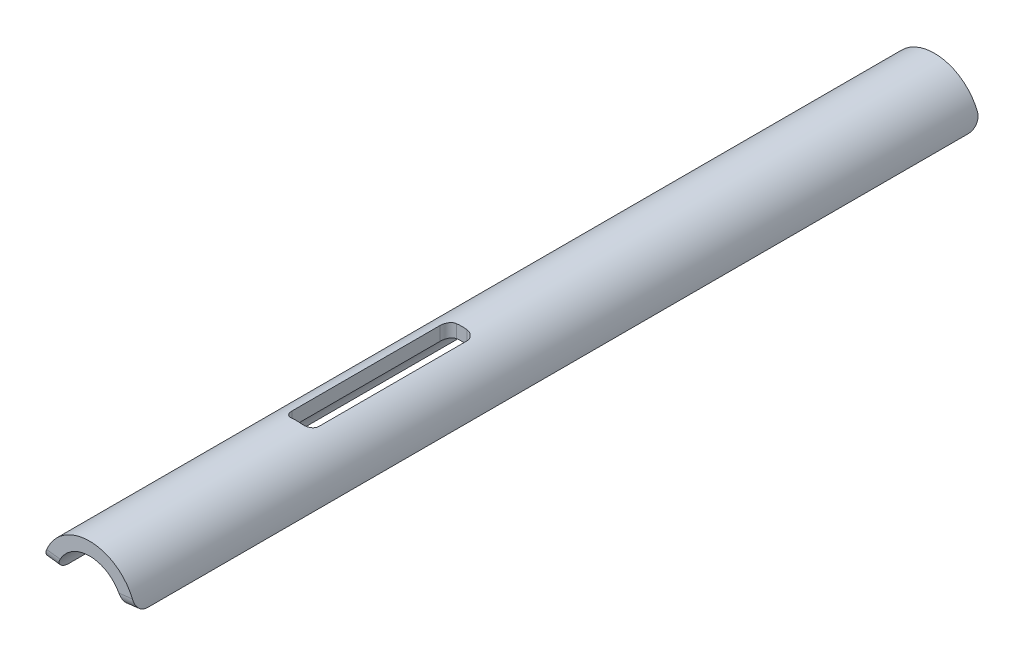
from build123d import *

# Parameters (mm, degrees)
BOSS_EXTRUDE1_DEPTH = 519.5
FILLET1_R           = 15
SKETCH2_W           = 33
SKETCH2_H           = 202
CUT_EXTRUDE1_DEPTH  = 57.9350001
FILLET2_R           = 10


with BuildPart() as part:
    # Sketch1 → Boss-Extrude1 (new body, symmetric)
    with BuildSketch(Plane.XY):
        with BuildLine():
            Line((40.754430434, 5), (56.51128828, 6.933146615))
            ThreePointArc((56.51128828, 6.933146615), (0, 56.935), (-56.51128828, 6.933146615))
            Line((-56.51128828, 6.933146615), (-40.754430434, 5))
            ThreePointArc((-40.754430434, 5), (0, 41.06), (40.754430434, 5))
        make_face()
    extrude(amount=BOSS_EXTRUDE1_DEPTH, both=True)

    # Fillet1
    fillet1_edges = [part.edges().sort_by_distance(p)[0] for p in [
        (-48.632859357, 5.966573307, 519.5),
        (-48.632859357, 5.966573307, -519.5),
        (48.632859357, 5.966573307, -519.5),
        (48.632859357, 5.966573307, 519.5),
    ]]
    fillet(fillet1_edges, radius=FILLET1_R)

    # Sketch2 → Cut-Extrude1 (cut, through all)
    with BuildSketch(Plane(origin=(0, 0, 0), x_dir=(1, 0, 0), z_dir=(0, 1, 0))):
        with Locations((0, -163)):
            Rectangle(SKETCH2_W, SKETCH2_H)
    extrude(amount=CUT_EXTRUDE1_DEPTH, mode=Mode.SUBTRACT)

    # Fillet2
    fillet2_edges = [part.edges().sort_by_distance(p)[0] for p in [
        (-16.5, 46.045270275, 62),
        (-16.5, 46.045270275, 264),
        (16.5, 46.045270275, 264),
        (16.5, 46.045270275, 62),
    ]]
    fillet(fillet2_edges, radius=FILLET2_R)


solid = part.part
